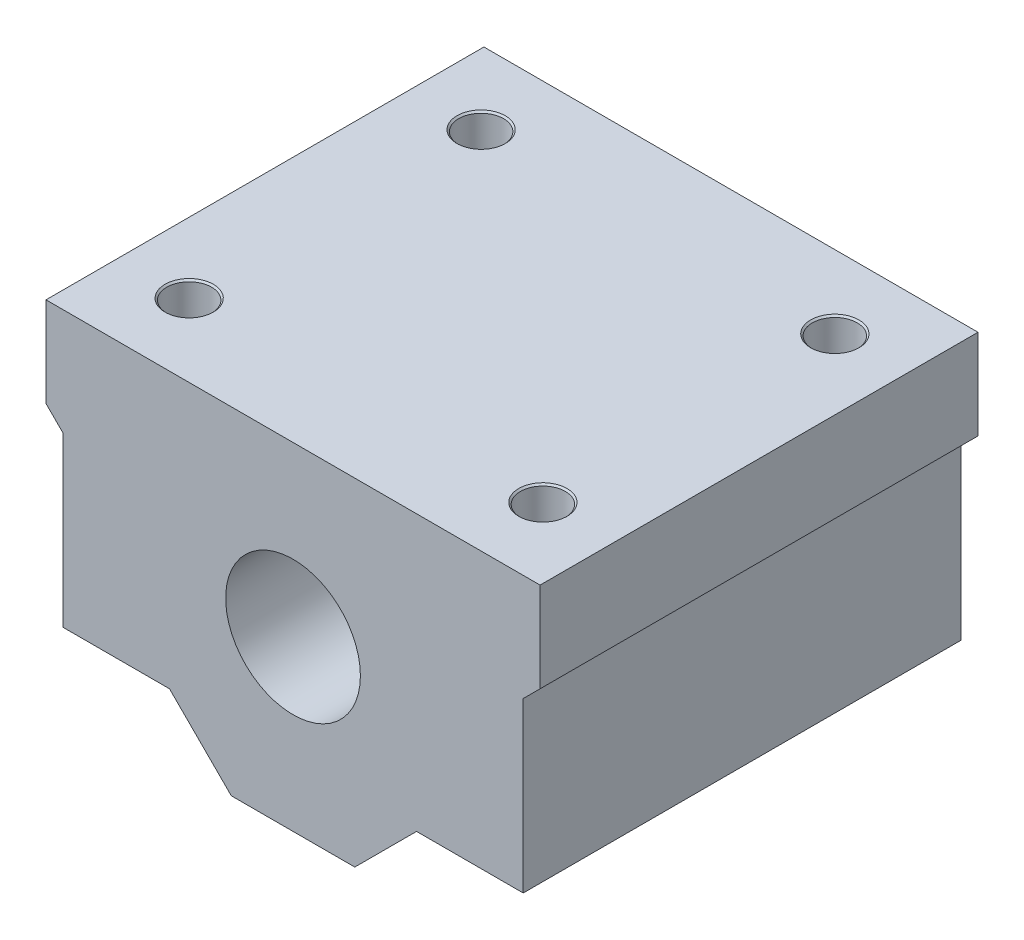
from build123d import *

# Parameters (mm, degrees)
IZIM2_R                     = 6
Y_KSEKLIK_EKSTR_ZYON1_DEPTH = 39
IZIM3_R                     = 2
KES_EKSTR_ZYON1_DEPTH       = 39
PAH1_SIZE                   = 0.15
PAH2_SIZE                   = 1.5


with BuildPart() as part:
    # Çizim2 → Yükseklik-Ekstrüzyon1 (new body)
    with BuildSketch(Plane.XY):
        Polygon((22, 15), (-22, 15), (-22, 7), (-20.5, 5.5), (-20.5, -9.5), (-11, -9.5), (-5.5, -15), (5.5, -15), (11, -9.5), (20.5, -9.5), (20.5, 5.5), (22, 7), align=None)
        Circle(IZIM2_R, mode=Mode.SUBTRACT)
    extrude(amount=Y_KSEKLIK_EKSTR_ZYON1_DEPTH)

    # Çizim3 → Kes-Ekstrüzyon1 (cut)
    with BuildSketch(Plane.XZ.offset(9.5)):
        with Locations((-15.75, 6.5)):
            Circle(IZIM3_R)
        with Locations((-15.75, 32.5)):
            Circle(IZIM3_R)
        with Locations((15.75, 6.5)):
            Circle(IZIM3_R)
        with Locations((15.75, 32.5)):
            Circle(IZIM3_R)
    extrude(amount=-KES_EKSTR_ZYON1_DEPTH, mode=Mode.SUBTRACT)

    # Pah1
    pah1_edges = [part.edges().sort_by_distance(p)[0] for p in [
        (-17.75, 15, 32.5),
        (13.75, 15, 6.5),
        (13.75, 15, 32.5),
        (-17.75, 15, 6.5),
    ]]
    chamfer(pah1_edges, length=PAH1_SIZE)

    # Pah2
    pah2_edges = [part.edges().sort_by_distance(p)[0] for p in [
        (-6, 0, 0),
    ]]
    chamfer(pah2_edges, length=PAH2_SIZE)


solid = part.part
